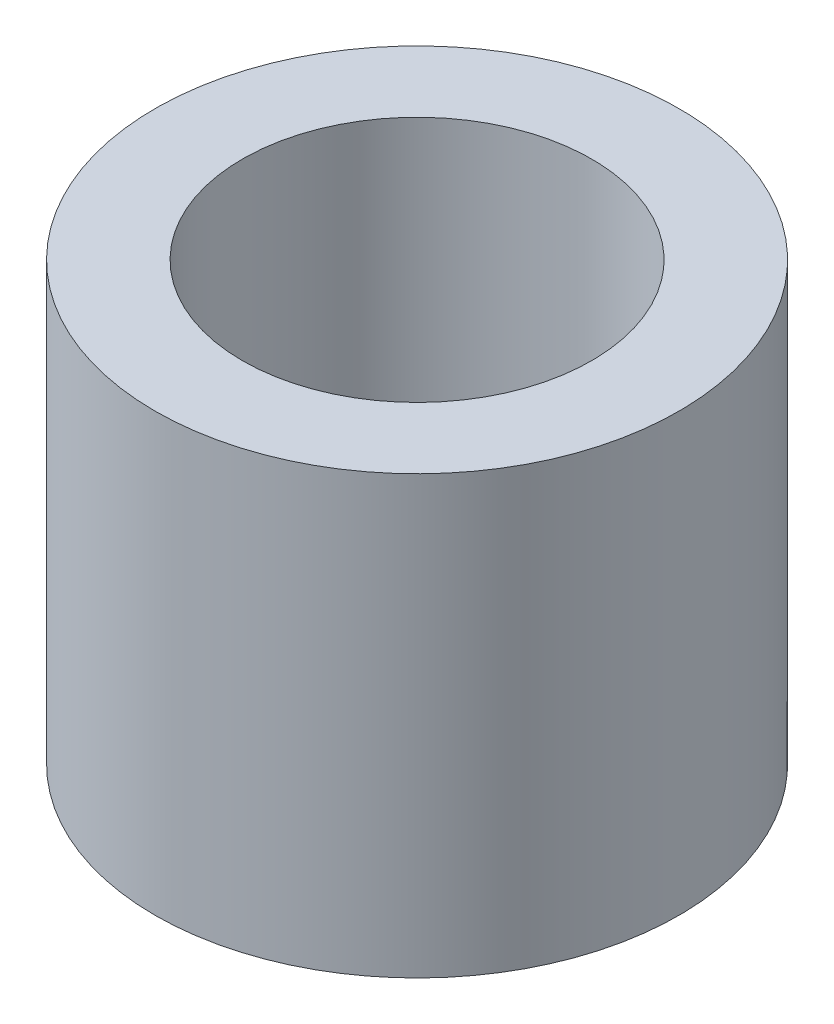
from build123d import *

# Parameters (mm, degrees)
SKETCH1_R           = 3
SKETCH1_R_2         = 2
BOSS_EXTRUDE1_DEPTH = 5


with BuildPart() as part:
    # Sketch1 → Boss-Extrude1 (new body)
    with BuildSketch(Plane(origin=(0, 0, 0), x_dir=(1, 0, 0), z_dir=(0, 1, 0))):
        with Locations((0, 0.265782308)):
            Circle(SKETCH1_R)
        with Locations((0, 0.265782308)):
            Circle(SKETCH1_R_2, mode=Mode.SUBTRACT)
    extrude(amount=BOSS_EXTRUDE1_DEPTH)


solid = part.part
